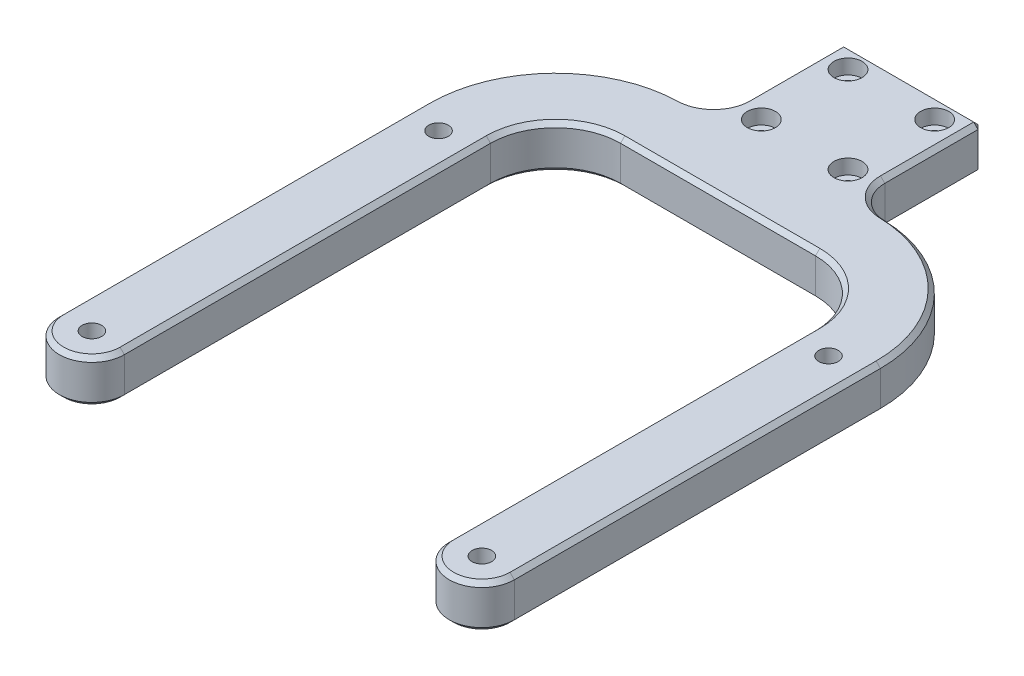
from build123d import *

# Parameters (mm, degrees)
SKETCH1_R                                           = 2.25
BOSS_EXTRUDE1_DEPTH                                 = 10
FILLET1_R                                           = 7.5
CHAMFER1_SIZE                                       = 1
SKETCH5_R                                           = 2.25
BOSS_EXTRUDE2_DEPTH                                 = 4
CBORE_FOR_M3_HEX_SOCKET_HEAD_CAP_SCREW1_D           = 3.4
CBORE_FOR_M3_HEX_SOCKET_HEAD_CAP_SCREW1_CBORE_D     = 6.5
CBORE_FOR_M3_HEX_SOCKET_HEAD_CAP_SCREW1_CBORE_DEPTH = 3.4


with BuildPart() as part:
    # Sketch1 → Boss-Extrude1 (new body)
    with BuildSketch(Plane(origin=(0, 0, 0), x_dir=(1, 0, 0), z_dir=(0, 1, 0))):
        with BuildLine():
            Line((0, 57.25), (22.5, 57.25))
            ThreePointArc((22.5, 57.25), (33.106601718, 52.856601718), (37.5, 42.25))
            Line((37.5, 42.25), (37.5, -42.25))
            ThreePointArc((37.5, -42.25), (45, -49.75), (52.5, -42.25))
            Line((52.5, -42.25), (52.5, 42.25))
            ThreePointArc((52.5, 42.25), (43.713203436, 63.463203436), (22.5, 72.25))
            Line((22.5, 72.25), (16, 72.25))
            Line((16, 72.25), (16, 102.25))
            Line((16, 102.25), (0, 102.25))
            Line((0, 102.25), (0, 57.25))
        make_face()
        with Locations((45, -42.25)):
            Circle(SKETCH1_R, mode=Mode.SUBTRACT)
        with Locations((45, 37.75)):
            Circle(SKETCH1_R, mode=Mode.SUBTRACT)
    extrude(amount=BOSS_EXTRUDE1_DEPTH)

    # Fillet1
    fillet1_edges = [part.edges().sort_by_distance(p)[0] for p in [
        (16, 5, -72.25),
    ]]
    fillet(fillet1_edges, radius=FILLET1_R)

    # Chamfer1
    chamfer1_edges = [part.edges().sort_by_distance(p)[0] for p in [
        (8, 0, -102.25),
        (43.99418526, 0, -63.178449536),
        (52.5, 0, 0),
        (45, 0, 49.75),
        (37.5, 0, 0),
        (33.106601718, 10, -52.856601718),
        (33.106601718, 0, -52.856601718),
        (11.25, 0, -57.25),
        (37.5, 10, 0),
        (16, 5, -102.25),
        (45, 10, 49.75),
        (52.5, 10, 0),
        (43.99418526, 10, -63.178449536),
        (16, 0, -90.993332148),
        (16, 10, -90.993332148),
        (8, 10, -102.25),
        (18.126453685, 0, -74.504551911),
        (18.126453685, 10, -74.504551911),
        (11.25, 10, -57.25),
    ]]
    chamfer(chamfer1_edges, length=CHAMFER1_SIZE)

    # Sketch5 → Boss-Extrude2 (add)
    with BuildSketch(Plane.XZ):
        with Locations((45, -37.75)):
            Circle(SKETCH5_R)
        with Locations((45, 42.25)):
            Circle(SKETCH5_R)
    extrude(amount=-BOSS_EXTRUDE2_DEPTH)

    # Mirror1: part across plane


with BuildPart() as part_1:
    add(part.part)
    add(part.part.mirror(Plane(origin=(0, 10, -57.25), x_dir=(0, 0, 1), z_dir=(1, 0, 0))))

    # CBORE for M3 Hex Socket Head Cap Screw1 (through all)
    with Locations(Plane(origin=(0, 10, 0), x_dir=(1, 0, 0), z_dir=(0, 1, 0))):
        with Locations((10, 97.25), (-10, 97.25), (-10, 77.25), (10, 77.25)):
            CounterBoreHole(CBORE_FOR_M3_HEX_SOCKET_HEAD_CAP_SCREW1_D / 2, CBORE_FOR_M3_HEX_SOCKET_HEAD_CAP_SCREW1_CBORE_D / 2, CBORE_FOR_M3_HEX_SOCKET_HEAD_CAP_SCREW1_CBORE_DEPTH)


solid = part_1.part
